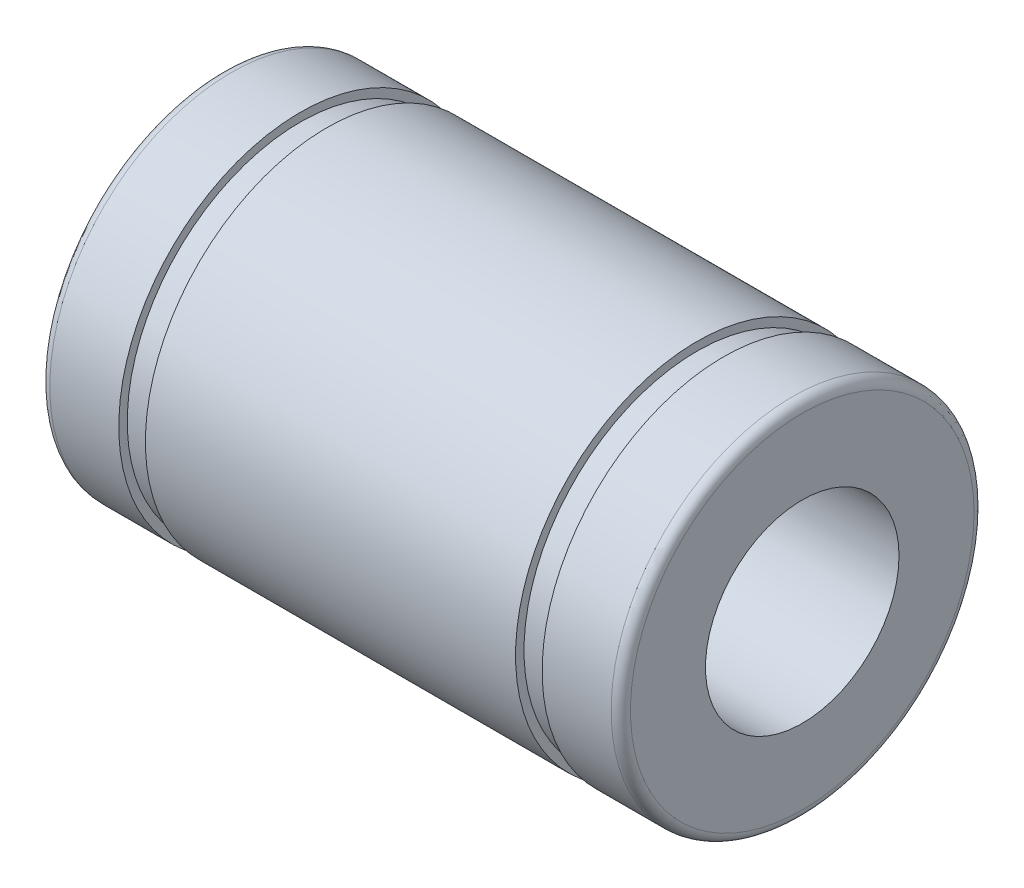
from build123d import *


with BuildPart() as part:
    # Sketch1 → Revolve1 (revolve)
    with BuildSketch(Plane.XY):
        with BuildLine():
            Line((0, 7.1), (0, 4))
            Line((0, 4), (24, 4))
            Line((24, 4), (24, 7.1))
            ThreePointArc((24, 7.1), (23.882842712, 7.382842712), (23.6, 7.5))
            Line((23.6, 7.5), (20.75, 7.5))
            Line((20.75, 7.5), (20.75, 7.15))
            Line((20.75, 7.15), (19.65, 7.15))
            Line((19.65, 7.15), (19.65, 7.5))
            Line((19.65, 7.5), (4.35, 7.5))
            Line((4.35, 7.5), (4.35, 7.15))
            Line((4.35, 7.15), (3.25, 7.15))
            Line((3.25, 7.15), (3.25, 7.5))
            Line((3.25, 7.5), (0.4, 7.5))
            ThreePointArc((0.4, 7.5), (0.117157288, 7.382842712), (0, 7.1))
        make_face()
    revolve(axis=Axis((-0.001253994, 0, 0), (1, 0, 0)))


solid = part.part
